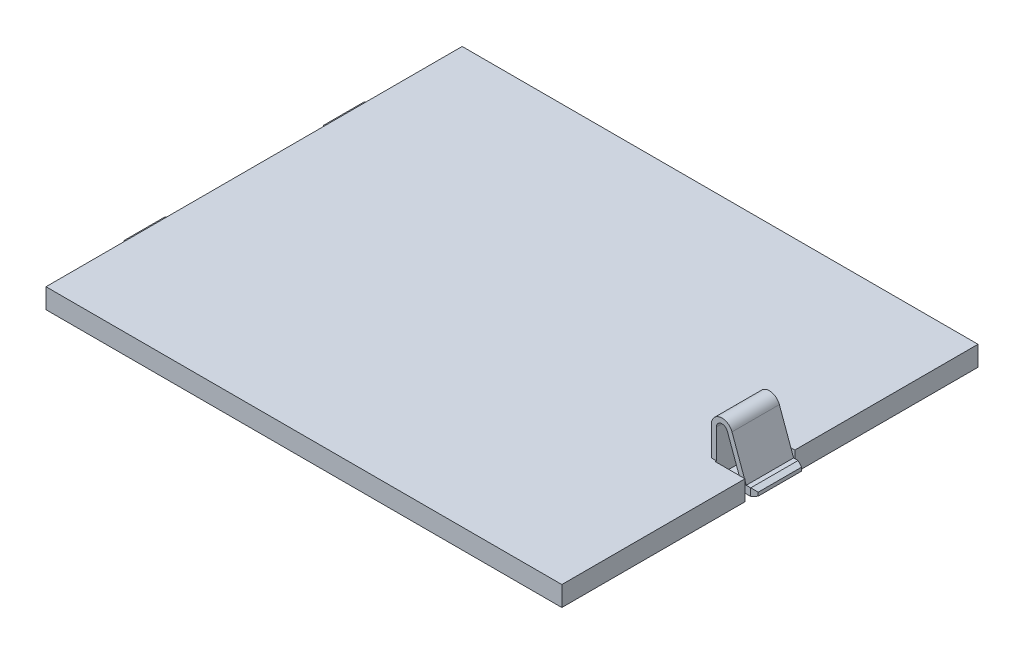
from build123d import *

# Parameters (mm, degrees)
BOSS_EXTRUDE1_DEPTH      = 4
CUT_EXTRUDE1_REACH       = 6
SKETCH3_W                = 6
SKETCH3_H                = 10
SKETCH4_W                = 2
SKETCH4_H                = 1.5
BOSS_EXTRUDE2_DEPTH      = 4.75
BOSS_EXTRUDE2_DEPTH_BACK = 4.75
SKETCH5_W                = 3
SKETCH5_H                = 6
CUT_EXTRUDE2_DEPTH       = 0.8
SKETCH6_W                = 2
SKETCH6_H                = 1.1
CUT_EXTRUDE3_DEPTH       = 67.5
CHAMFER3_SIZE            = 0.4
CHAMFER3_SIZE2           = 1.098990968
CHAMFER4_SIZE            = 0.7
CHAMFER4_SIZE2           = 1.923234194
CHAMFER4_PART_2_SIZE     = 0.7
CHAMFER4_PART_2_SIZE2    = 1.923234194


with BuildPart() as part:
    # Sketch1 → Boss-Extrude1 (new body)
    with BuildSketch(Plane(origin=(0, 0, 0), x_dir=(1, 0, 0), z_dir=(0, 1, 0))):
        Polygon((-51.75, 24.75), (-51.75, 41.75), (51.75, 41.75), (51.75, -41.75), (-51.75, -41.75), (-51.75, -24.75), (-53.75, -24.75), (-53.75, -15.25), (-51.75, -15.25), (-51.75, 15.25), (-53.75, 15.25), (-53.75, 24.75), align=None)
    extrude(amount=BOSS_EXTRUDE1_DEPTH)

    # Sketch3 → Cut-Extrude1 (cut, up to next)
    with BuildSketch(Plane(origin=(0, 4, 0), x_dir=(1, 0, 0), z_dir=(0, 1, 0)), mode=Mode.PRIVATE) as cut_extrude1_sk1:
        with Locations((48.75, 0)):
            Rectangle(SKETCH3_W, SKETCH3_H)
    cut_extrude1_tool1 = extrude(cut_extrude1_sk1.sketch, amount=-CUT_EXTRUDE1_REACH, mode=Mode.PRIVATE) & part.part
    add(cut_extrude1_tool1.solids().sort_by_distance((48.75, 4, 0))[0], mode=Mode.SUBTRACT)

    # Sketch4 → Boss-Extrude2 (add, two sides)
    with BuildSketch(Plane.XY) as boss_extrude2_sk:
        with BuildLine():
            Line((44.75, 4), (45.75, 4))
            Line((45.75, 4), (45.75, 9.863040099))
            ThreePointArc((45.75, 9.863040099), (46.689528886, 10.982727024), (47.955352731, 10.251903287))
            Line((47.955352731, 10.251903287), (50.321851993, 3.75))
            Line((50.321851993, 3.75), (48.25, 3.75))
            Line((48.25, 3.75), (48.25, 1.25))
            Line((48.25, 1.25), (51.75, 1.25))
            Line((51.75, 1.25), (51.75, 2.75))
            Line((51.75, 2.75), (48.895045351, 10.59392343))
            ThreePointArc((48.895045351, 10.59392343), (46.515880709, 11.967534777), (44.75, 9.863040099))
            Line((44.75, 9.863040099), (44.75, 4))
        make_face()
        with Locations((52.75, 2)):
            Rectangle(SKETCH4_W, SKETCH4_H)
    extrude(amount=BOSS_EXTRUDE2_DEPTH)
    extrude(boss_extrude2_sk.sketch, amount=-BOSS_EXTRUDE2_DEPTH_BACK)

    # Sketch5 → Cut-Extrude2 (cut)
    with BuildSketch(Plane.XZ.offset(-1.25)):
        with Locations((50.25, 0)):
            Rectangle(SKETCH5_W, SKETCH5_H)
    extrude(amount=-CUT_EXTRUDE2_DEPTH, mode=Mode.SUBTRACT)

    # Sketch6 → Cut-Extrude3 (cut, through all)
    with BuildSketch(Plane.XY.offset(24.75)):
        with Locations((-52.75, 3.45)):
            Rectangle(SKETCH6_W, SKETCH6_H)
        with Locations((-52.75, 0.55)):
            Rectangle(SKETCH6_W, SKETCH6_H)
    extrude(amount=-CUT_EXTRUDE3_DEPTH, mode=Mode.SUBTRACT)

    # Chamfer3
    chamfer3_edges = [part.edges().sort_by_distance(p)[0] for p in [
        (53.75, 2.75, 0),
        (53.75, 2, 4.75),
        (53.75, 1.25, 0),
        (53.75, 2, -4.75),
    ]]
    chamfer3_side = [part.faces().sort_by_distance(p)[0] for p in [
        (53.75, 2, 0),
    ]]
    chamfer(chamfer3_edges, length=CHAMFER3_SIZE, length2=CHAMFER3_SIZE2, reference=chamfer3_side[0])

    # Chamfer4
    chamfer4_edges = [part.edges().sort_by_distance(p)[0] for p in [
        (-53.75, 2, 15.25),
        (-53.75, 2.9, 20),
        (-53.75, 1.1, 20),
        (-53.75, 2, 24.75),
    ]]
    chamfer4_side = [part.faces().sort_by_distance(p)[0] for p in [
        (-53.75, 2, 20),
    ]]
    chamfer(chamfer4_edges, length=CHAMFER4_SIZE, length2=CHAMFER4_SIZE2, reference=chamfer4_side[0])

    # Chamfer4 part 2
    chamfer4_part_2_edges = [part.edges().sort_by_distance(p)[0] for p in [
        (-53.75, 2, -15.25),
        (-53.75, 2, -24.75),
        (-53.75, 2.9, -20),
        (-53.75, 1.1, -20),
    ]]
    chamfer4_part_2_side = [part.faces().sort_by_distance(p)[0] for p in [
        (-53.75, 2, -20),
    ]]
    chamfer(chamfer4_part_2_edges, length=CHAMFER4_PART_2_SIZE, length2=CHAMFER4_PART_2_SIZE2, reference=chamfer4_part_2_side[0])


solid = part.part
